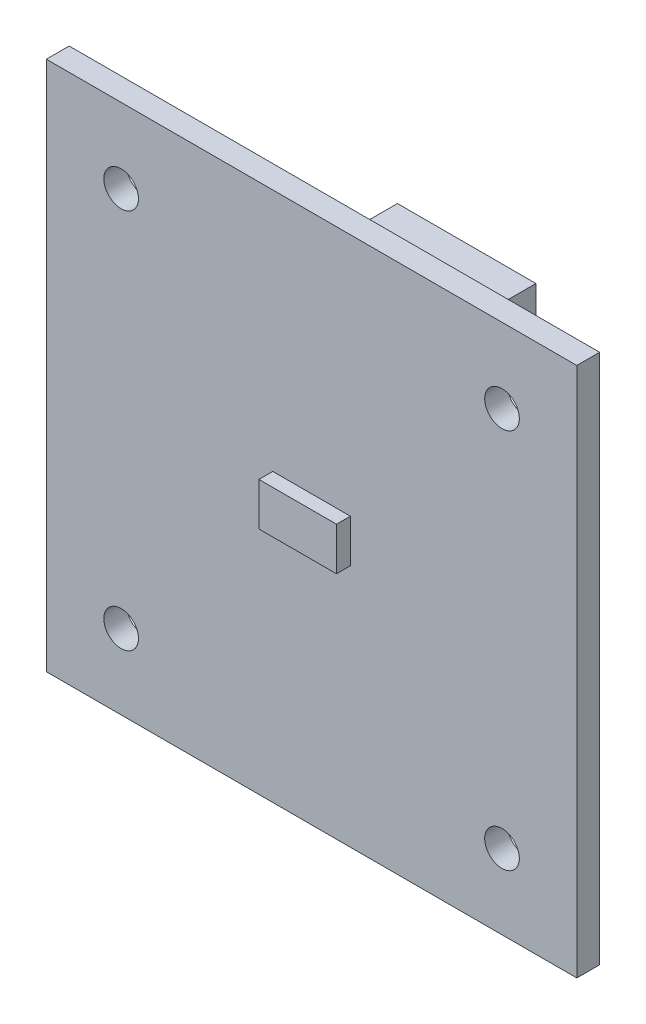
from build123d import *

# Parameters (mm, degrees)
SKIZZE1_W                       = 38.3
SKIZZE1_H                       = 38.3
SKIZZE1_R                       = 1.25
AUFSATZ_LINEAR_AUSTRAGEN1_DEPTH = 1.65
SKIZZE2_W                       = 5.6
SKIZZE2_H                       = 3.1
AUFSATZ_LINEAR_AUSTRAGEN2_DEPTH = 1
SKETCH2_W                       = 10
SKETCH2_H                       = 4.7
BOSS_EXTRUDE1_DEPTH             = 6


with BuildPart() as part:
    # Skizze1 → Aufsatz-Linear austragen1 (new body)
    with BuildSketch(Plane.XY):
        Rectangle(SKIZZE1_W, SKIZZE1_H)
        with Locations((-13.75, 13.75)):
            Circle(SKIZZE1_R, mode=Mode.SUBTRACT)
        with Locations((13.75, 13.75)):
            Circle(SKIZZE1_R, mode=Mode.SUBTRACT)
        with Locations((13.75, -13.75)):
            Circle(SKIZZE1_R, mode=Mode.SUBTRACT)
        with Locations((-13.75, -13.75)):
            Circle(SKIZZE1_R, mode=Mode.SUBTRACT)
    extrude(amount=AUFSATZ_LINEAR_AUSTRAGEN1_DEPTH)

    # Skizze2 → Aufsatz-Linear austragen2 (add)
    with BuildSketch(Plane.XY.offset(1.65)):
        Rectangle(SKIZZE2_W, SKIZZE2_H)
    extrude(amount=AUFSATZ_LINEAR_AUSTRAGEN2_DEPTH)

    # Sketch2 → Boss-Extrude1 (add)
    with BuildSketch(Plane(origin=(0, 0, 0), x_dir=(-1, 0, 0), z_dir=(0, 0, -1))):
        with Locations((-3.55, 12.8)):
            Rectangle(SKETCH2_W, SKETCH2_H)
    extrude(amount=BOSS_EXTRUDE1_DEPTH)


solid = part.part
